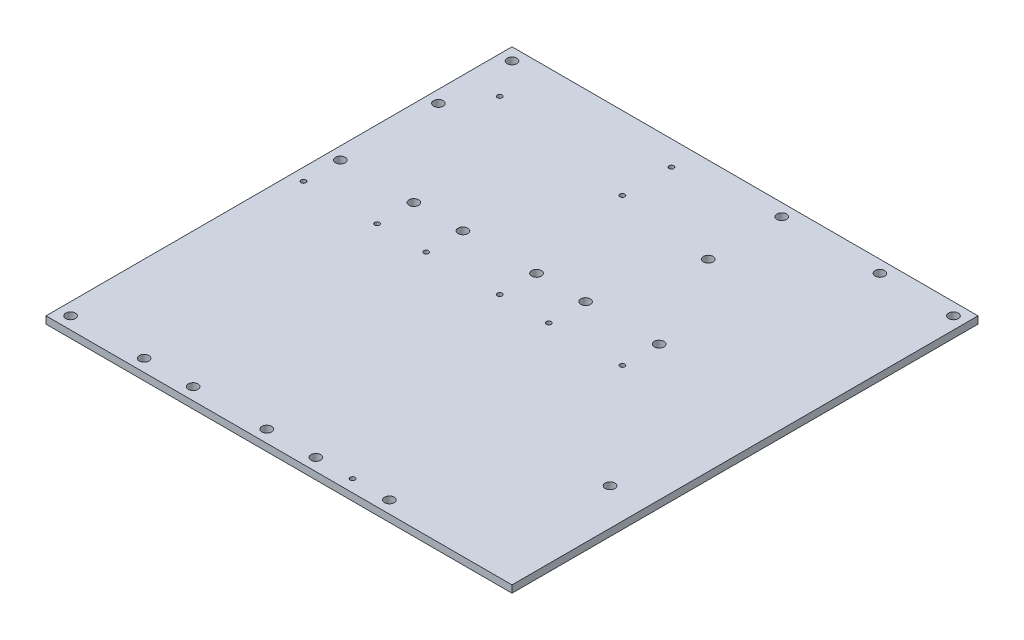
from build123d import *

# Parameters (mm, degrees)
SKETCH1_W           = 60.96
SKETCH1_H           = 20.32
SKETCH1_R           = 1
SKETCH1_R_2         = 0.5
SKETCH1_W_2         = 20.32
SKETCH1_H_2         = 81.28
SKETCH1_H_3         = 60.96
BOSS_EXTRUDE1_DEPTH = 1.5
SKETCH1_4_R         = 0.5
CUT_EXTRUDE1_DEPTH  = 0.762


with BuildPart() as part:
    # Sketch1 → Boss-Extrude1 (new body)
    with BuildSketch(Plane(origin=(0, 0, 0), x_dir=(1, 0, 0), z_dir=(0, 1, 0))):
        with Locations((30.48, 10.16)):
            Rectangle(SKETCH1_W, SKETCH1_H)
        with Locations(Location((2.54, 17.78, 0), (0, 0, 270))):  # turned: the seam where the file's is
            Circle(SKETCH1_R, mode=Mode.SUBTRACT)
        with Locations(Location((58.42, 17.78, 0), (0, 0, 270))):  # turned: the seam where the file's is
            Circle(SKETCH1_R, mode=Mode.SUBTRACT)
        with Locations(Location((2.54, 2.54, 0), (0, 0, 270))):  # turned: the seam where the file's is
            Circle(SKETCH1_R, mode=Mode.SUBTRACT)
        with Locations(Location((58.42, 2.54, 0), (0, 0, 270))):  # turned: the seam where the file's is
            Circle(SKETCH1_R, mode=Mode.SUBTRACT)
        with Locations(Location((38.1, 5.08, 0), (0, 0, 270))):  # turned: the seam where the file's is
            Circle(SKETCH1_R_2, mode=Mode.SUBTRACT)
        with Locations(Location((7.62, 10.16, 0), (0, 0, 270))):  # turned: the seam where the file's is
            Circle(SKETCH1_R_2, mode=Mode.SUBTRACT)
        with Locations(Location((38.1, 15.24, 0), (0, 0, 270))):  # turned: the seam where the file's is
            Circle(SKETCH1_R_2, mode=Mode.SUBTRACT)
        Polygon((60.96, 0), (0, 0), (0, -15.24), (20.32, -15.24), (20.32, -76.2), (25.4, -76.2), (25.4, -15.24), (45.72, -15.24), (45.72, -76.2), (50.8, -76.2), (50.8, -15.24), (71.12, -15.24), (71.12, -76.2), (96.52, -76.2), (96.52, -60.96), (76.2, -60.96), (76.2, 20.32), (60.96, 20.32), align=None)
        with Locations((86.36, -20.32)):
            Rectangle(SKETCH1_W_2, SKETCH1_H_2)
        with Locations((86.36, -58.42)):
            Circle(SKETCH1_R_2, mode=Mode.SUBTRACT)
        with Locations((88.9, -58.42)):
            Circle(SKETCH1_R_2, mode=Mode.SUBTRACT)
        with Locations(Location((88.9, -48.277647537, 0), (0, 0, 270))):  # turned: the seam where the file's is
            Circle(SKETCH1_R, mode=Mode.SUBTRACT)
        with Locations(Location((78.74, 17.78, 0), (0, 0, 270))):  # turned: the seam where the file's is
            Circle(SKETCH1_R, mode=Mode.SUBTRACT)
        with Locations((83.82, 17.78)):
            Circle(SKETCH1_R_2, mode=Mode.SUBTRACT)
        with Locations((86.36, 17.78)):
            Circle(SKETCH1_R_2, mode=Mode.SUBTRACT)
        with Locations(Location((93.98, 17.78, 0), (0, 0, 270))):  # turned: the seam where the file's is
            Circle(SKETCH1_R, mode=Mode.SUBTRACT)
        with Locations((10.16, -45.72)):
            Rectangle(SKETCH1_W_2, SKETCH1_H_3)
        with Locations(Location((2.54, -73.66, 0), (0, 0, 270))):  # turned: the seam where the file's is
            Circle(SKETCH1_R, mode=Mode.SUBTRACT)
        with Locations((8.636, -71.12)):
            Circle(SKETCH1_R_2, mode=Mode.SUBTRACT)
        with Locations((11.176, -71.12)):
            Circle(SKETCH1_R_2, mode=Mode.SUBTRACT)
        with Locations(Location((17.78, -73.66, 0), (0, 0, 270))):  # turned: the seam where the file's is
            Circle(SKETCH1_R, mode=Mode.SUBTRACT)
        with Locations(Location((2.54, -25.4, 0), (0, 0, 270))):  # turned: the seam where the file's is
            Circle(SKETCH1_R_2, mode=Mode.SUBTRACT)
        with Locations(Location((2.54, -17.78, 0), (0, 0, 270))):  # turned: the seam where the file's is
            Circle(SKETCH1_R, mode=Mode.SUBTRACT)
        with Locations(Location((17.78, -25.4, 0), (0, 0, 270))):  # turned: the seam where the file's is
            Circle(SKETCH1_R_2, mode=Mode.SUBTRACT)
        with Locations(Location((17.78, -17.78, 0), (0, 0, 270))):  # turned: the seam where the file's is
            Circle(SKETCH1_R, mode=Mode.SUBTRACT)
        Polygon((60.96, 0), (0, 0), (0, -15.24), (20.32, -15.24), (20.32, -76.2), (25.4, -76.2), (25.4, -15.24), (45.72, -15.24), (45.72, -76.2), (50.8, -76.2), (50.8, -15.24), (71.12, -15.24), (71.12, -76.2), (96.52, -76.2), (96.52, -60.96), (76.2, -60.96), (76.2, 20.32), (60.96, 20.32), align=None)
        with Locations((60.96, -45.72)):
            Rectangle(SKETCH1_W_2, SKETCH1_H_3)
        with Locations(Location((53.34, -73.66, 0), (0, 0, 270))):  # turned: the seam where the file's is
            Circle(SKETCH1_R, mode=Mode.SUBTRACT)
        with Locations(Location((60.96, -73.66, 0), (0, 0, 270))):  # turned: the seam where the file's is
            Circle(SKETCH1_R_2, mode=Mode.SUBTRACT)
        with Locations(Location((68.58, -73.66, 0), (0, 0, 270))):  # turned: the seam where the file's is
            Circle(SKETCH1_R, mode=Mode.SUBTRACT)
        with Locations(Location((53.34, -25.4, 0), (0, 0, 270))):  # turned: the seam where the file's is
            Circle(SKETCH1_R_2, mode=Mode.SUBTRACT)
        with Locations(Location((53.34, -17.78, 0), (0, 0, 270))):  # turned: the seam where the file's is
            Circle(SKETCH1_R, mode=Mode.SUBTRACT)
        with Locations(Location((68.58, -25.4, 0), (0, 0, 270))):  # turned: the seam where the file's is
            Circle(SKETCH1_R_2, mode=Mode.SUBTRACT)
        with Locations(Location((68.58, -17.78, 0), (0, 0, 270))):  # turned: the seam where the file's is
            Circle(SKETCH1_R, mode=Mode.SUBTRACT)
        with Locations((35.56, -45.72)):
            Rectangle(SKETCH1_W_2, SKETCH1_H_3)
        with Locations(Location((27.94, -73.66, 0), (0, 0, 270))):  # turned: the seam where the file's is
            Circle(SKETCH1_R, mode=Mode.SUBTRACT)
        with Locations((34.036, -68.58)):
            Circle(SKETCH1_R_2, mode=Mode.SUBTRACT)
        with Locations(Location((43.18, -73.66, 0), (0, 0, 270))):  # turned: the seam where the file's is
            Circle(SKETCH1_R, mode=Mode.SUBTRACT)
        with Locations((36.576, -68.58)):
            Circle(SKETCH1_R_2, mode=Mode.SUBTRACT)
        with Locations(Location((27.94, -25.4, 0), (0, 0, 270))):  # turned: the seam where the file's is
            Circle(SKETCH1_R_2, mode=Mode.SUBTRACT)
        with Locations(Location((27.94, -17.78, 0), (0, 0, 270))):  # turned: the seam where the file's is
            Circle(SKETCH1_R, mode=Mode.SUBTRACT)
        with Locations(Location((43.18, -25.4, 0), (0, 0, 270))):  # turned: the seam where the file's is
            Circle(SKETCH1_R_2, mode=Mode.SUBTRACT)
        with Locations(Location((43.18, -17.78, 0), (0, 0, 270))):  # turned: the seam where the file's is
            Circle(SKETCH1_R, mode=Mode.SUBTRACT)
        with Locations((88.9, -58.42)):
            Circle(SKETCH1_R_2)
        with Locations((86.36, -58.42)):
            Circle(SKETCH1_R_2)
        with Locations((86.36, 17.78)):
            Circle(SKETCH1_R_2)
        with Locations((83.82, 17.78)):
            Circle(SKETCH1_R_2)
        with Locations((36.576, -68.58)):
            Circle(SKETCH1_R_2)
        with Locations((34.036, -68.58)):
            Circle(SKETCH1_R_2)
        with Locations((11.176, -71.12)):
            Circle(SKETCH1_R_2)
        with Locations((8.636, -71.12)):
            Circle(SKETCH1_R_2)
    extrude(amount=BOSS_EXTRUDE1_DEPTH)

    # Sketch1_4 → Cut-Extrude1 (cut)
    with BuildSketch(Plane(origin=(0, 0, 0), x_dir=(1, 0, 0), z_dir=(0, 1, 0))):
        with Locations(Location((86.36, 17.78, 0), (0, 0, 270))):  # turned: the seam where the file's is
            Circle(SKETCH1_4_R)
        with Locations(Location((83.82, 17.78, 0), (0, 0, 270))):  # turned: the seam where the file's is
            Circle(SKETCH1_4_R)
        with Locations(Location((86.36, -58.42, 0), (0, 0, 270))):  # turned: the seam where the file's is
            Circle(SKETCH1_4_R)
        with Locations(Location((88.9, -58.42, 0), (0, 0, 270))):  # turned: the seam where the file's is
            Circle(SKETCH1_4_R)
        with Locations(Location((36.576, -68.58, 0), (0, 0, 270))):  # turned: the seam where the file's is
            Circle(SKETCH1_4_R)
        with Locations(Location((34.036, -68.58, 0), (0, 0, 270))):  # turned: the seam where the file's is
            Circle(SKETCH1_4_R)
        with Locations(Location((11.176, -71.12, 0), (0, 0, 270))):  # turned: the seam where the file's is
            Circle(SKETCH1_4_R)
        with Locations(Location((8.636, -71.12, 0), (0, 0, 270))):  # turned: the seam where the file's is
            Circle(SKETCH1_4_R)
    extrude(amount=CUT_EXTRUDE1_DEPTH, mode=Mode.SUBTRACT)


solid = part.part
